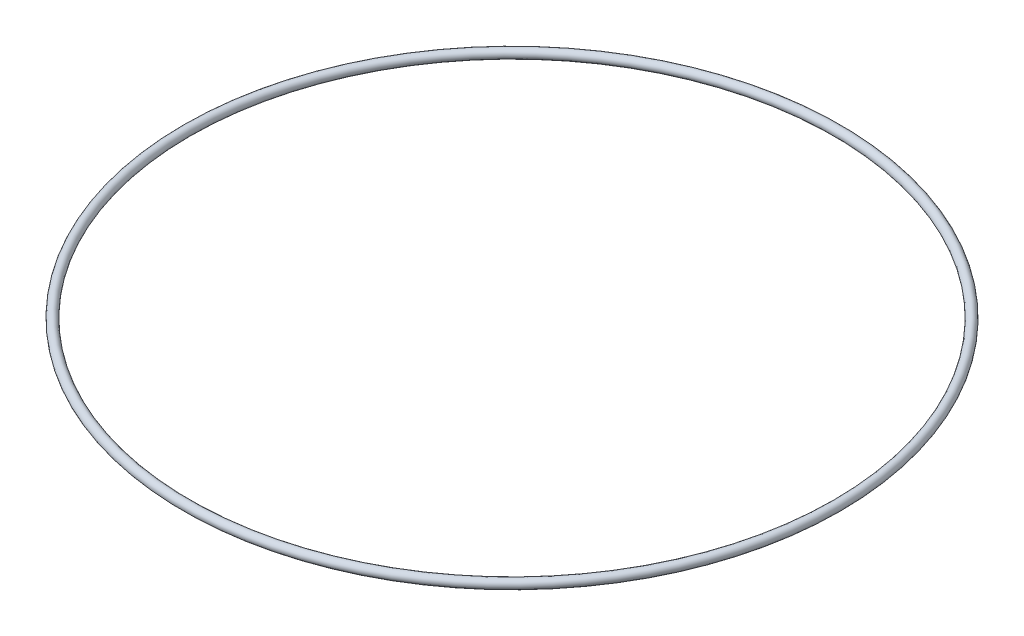
from build123d import *

# Parameters (mm, degrees)
SKETCH1_R = 0.79375


with BuildPart() as part:
    # Sketch1 → Revolve1 (revolve)
    with BuildSketch(Plane.XY):
        with Locations((56.515, 3.175)):
            Circle(SKETCH1_R)
    revolve(axis=Axis((0, -29.061636637, 0), (0, 1, 0)))


solid = part.part
